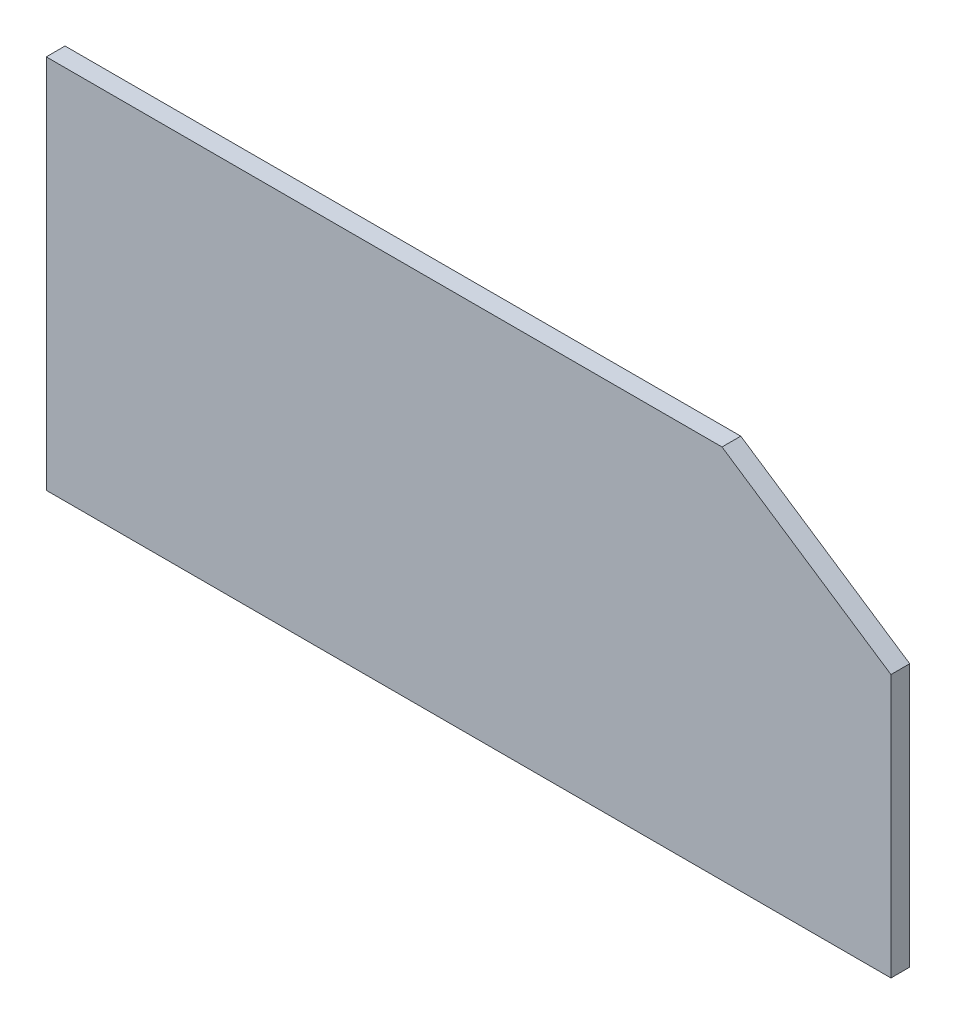
from build123d import *

# Parameters (mm, degrees)
BOSS_EXTRUDE1_DEPTH = 1.5875


with BuildPart() as part:
    # Sketch1 → Boss-Extrude1 (new body, symmetric)
    with BuildSketch(Plane.XY):
        Polygon((-150.011928505, -117.303446964), (-7.136928505, -117.303446964), (-7.136928505, -72.853446964), (-35.711928505, -53.803446964), (-150.011928505, -53.803446964), align=None)
    extrude(amount=BOSS_EXTRUDE1_DEPTH, both=True)


solid = part.part
